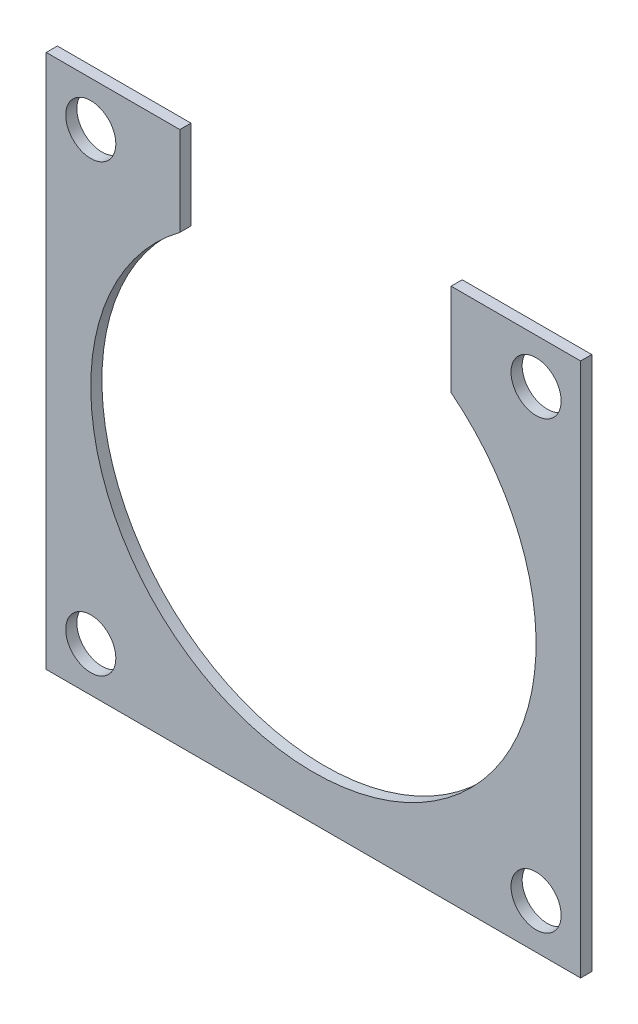
from build123d import *

# Parameters (mm, degrees)
SKETCH1_W               = 76.2
SKETCH1_H               = 76.2
SKETCH1_R               = 31.75
BOSS_EXTRUDE1_DEPTH     = 1.5875
SKETCH2_R               = 3.572453457
CUT_EXTRUDE1_DEPTH      = 3.175
SKETCH5_W               = 38.678922036
SKETCH5_H               = 46.509488783
CUT_EXTRUDE3_DEPTH      = 2.5875
MIRROR2_COPY_1_SKETCH_R = 3.572453457
MIRROR2_COPY_1_DEPTH    = 3.175


with BuildPart() as part:
    # Sketch1 → Boss-Extrude1 (new body)
    with BuildSketch(Plane.XY):
        Rectangle(SKETCH1_W, SKETCH1_H)
        Circle(SKETCH1_R, mode=Mode.SUBTRACT)
    extrude(amount=BOSS_EXTRUDE1_DEPTH)

    # Sketch2 → Cut-Extrude1 (cut)
    with BuildSketch(Plane.XY.offset(1.5875)):
        with Locations((-31.75, 31.75)):
            Circle(SKETCH2_R)
    cut_extrude1 = extrude(amount=-CUT_EXTRUDE1_DEPTH, mode=Mode.SUBTRACT)

    # Sketch5 → Cut-Extrude3 (cut, through all)
    with BuildSketch(Plane.XY.offset(1.5875)):
        with Locations((0.289461018, 41.034744392)):
            Rectangle(SKETCH5_W, SKETCH5_H)
    extrude(amount=-CUT_EXTRUDE3_DEPTH, mode=Mode.SUBTRACT)

    # Mirror1: Cut-Extrude1 across plane
    add(cut_extrude1.mirror(Plane(origin=(0, 0, 0), x_dir=(0, 0, 1), z_dir=(1, 0, 0))), mode=Mode.SUBTRACT)

    # Mirror2: Cut-Extrude1 across plane
    add(cut_extrude1.mirror(Plane.ZX), mode=Mode.SUBTRACT)

    # Mirror2 copy 1 sketch → Mirror2 copy 1 (cut)
    with BuildSketch(Plane(origin=(0, 0, 1.5875), x_dir=(-1, 0, 0), z_dir=(0, 0, 1))):
        with Locations((-31.75, 31.75)):
            Circle(MIRROR2_COPY_1_SKETCH_R)
    extrude(amount=-MIRROR2_COPY_1_DEPTH, mode=Mode.SUBTRACT)


solid = part.part
